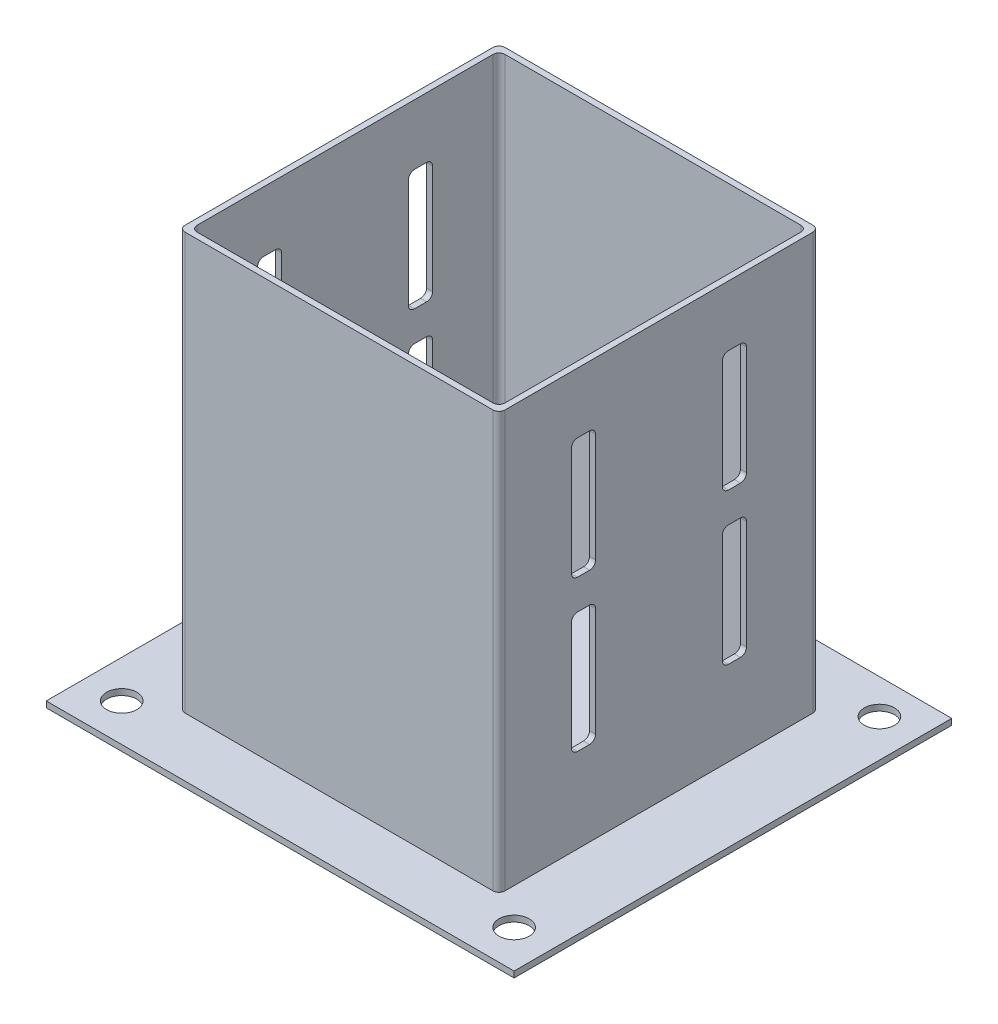
from build123d import *

# Parameters (mm, degrees)
SKETCH1_W              = 106
SKETCH1_H              = 106
SKETCH1_W_2            = 102
SKETCH1_H_2            = 102
BOSS_EXTRUDE1_DEPTH    = 140
SKETCH2_W              = 155
SKETCH2_H              = 145
BOSS_EXTRUDE2_DEPTH    = 2
SKETCH3_R              = 5
CUT_EXTRUDE1_DEPTH     = 2
CUT_EXTRUDE2_START     = -131.5
CUT_EXTRUDE2_DEPTH     = 157
LPATTERN1_COUNT        = 2
LPATTERN1_PITCH        = 50
LPATTERN1_START        = -131.5
LPATTERN1_COPY_1_DEPTH = 157
FILLET1_R              = 2


with BuildPart() as part:
    # Sketch1 → Boss-Extrude1 (new body)
    with BuildSketch(Plane(origin=(0, 0, 0), x_dir=(1, 0, 0), z_dir=(0, 1, 0))):
        Rectangle(SKETCH1_W, SKETCH1_H)
        Rectangle(SKETCH1_W_2, SKETCH1_H_2, mode=Mode.SUBTRACT)
    extrude(amount=BOSS_EXTRUDE1_DEPTH)

    # Sketch2 → Boss-Extrude2 (add)
    with BuildSketch(Plane(origin=(0, 0, 0), x_dir=(1, 0, 0), z_dir=(0, 1, 0))):
        Rectangle(SKETCH2_W, SKETCH2_H)
    extrude(amount=BOSS_EXTRUDE2_DEPTH)

    # Sketch3 → Cut-Extrude1 (cut)
    with BuildSketch(Plane(origin=(0, 2, 0), x_dir=(1, 0, 0), z_dir=(0, 1, 0))):
        with Locations((-65, 61.040230774)):
            Circle(SKETCH3_R)
        with Locations((65, 61.040230774)):
            Circle(SKETCH3_R)
        with Locations((65, -60)):
            Circle(SKETCH3_R)
        with Locations((-65, -60)):
            Circle(SKETCH3_R)
    extrude(amount=-CUT_EXTRUDE1_DEPTH, mode=Mode.SUBTRACT)

    # Sketch4 → Cut-Extrude2 (cut)
    with BuildSketch(Plane(origin=(53, 0, 0), x_dir=(0, 0, -1), z_dir=(1, 0, 0)).offset(CUT_EXTRUDE2_START)):
        with BuildLine():
            Line((-23, 80), (-27, 80))
            ThreePointArc((-27, 80), (-28.414213562, 80.585786438), (-29, 82))
            Line((-29, 82), (-29, 118))
            ThreePointArc((-29, 118), (-28.414213562, 119.414213562), (-27, 120))
            Line((-27, 120), (-23, 120))
            ThreePointArc((-23, 120), (-21.585786438, 119.414213562), (-21, 118))
            Line((-21, 118), (-21, 82))
            ThreePointArc((-21, 82), (-21.585786438, 80.585786438), (-23, 80))
        make_face()
    cut_extrude2 = extrude(amount=CUT_EXTRUDE2_DEPTH, mode=Mode.SUBTRACT)

    # Mirror1: Cut-Extrude2 across plane
    add(cut_extrude2.mirror(Plane.XY), mode=Mode.SUBTRACT)

    # LPattern1: Cut-Extrude2 ×2
    with Locations(*[(0, -i * LPATTERN1_PITCH, 0) for i in range(1, LPATTERN1_COUNT)]):
        add(cut_extrude2, mode=Mode.SUBTRACT)

    # LPattern1 copy 1 sketch → LPattern1 copy 1 (cut)
    with BuildSketch(Plane(origin=(53, -50, 0), x_dir=(0, 0, 1), z_dir=(1, 0, 0)).offset(LPATTERN1_START)):
        with BuildLine():
            Line((-23, -80), (-27, -80))
            ThreePointArc((-27, -80), (-28.414213562, -80.585786438), (-29, -82))
            Line((-29, -82), (-29, -118))
            ThreePointArc((-29, -118), (-28.414213562, -119.414213562), (-27, -120))
            Line((-27, -120), (-23, -120))
            ThreePointArc((-23, -120), (-21.585786438, -119.414213562), (-21, -118))
            Line((-21, -118), (-21, -82))
            ThreePointArc((-21, -82), (-21.585786438, -80.585786438), (-23, -80))
        make_face()
    extrude(amount=LPATTERN1_COPY_1_DEPTH, mode=Mode.SUBTRACT)

    # Fillet1
    fillet1_edges = [part.edges().sort_by_distance(p)[0] for p in [
        (-51, 71, -51),
        (-51, 71, 51),
        (51, 71, 51),
        (51, 71, -51),
        (-53, 71, -53),
        (53, 71, -53),
        (53, 71, 53),
        (-53, 71, 53),
    ]]
    fillet(fillet1_edges, radius=FILLET1_R)


solid = part.part
